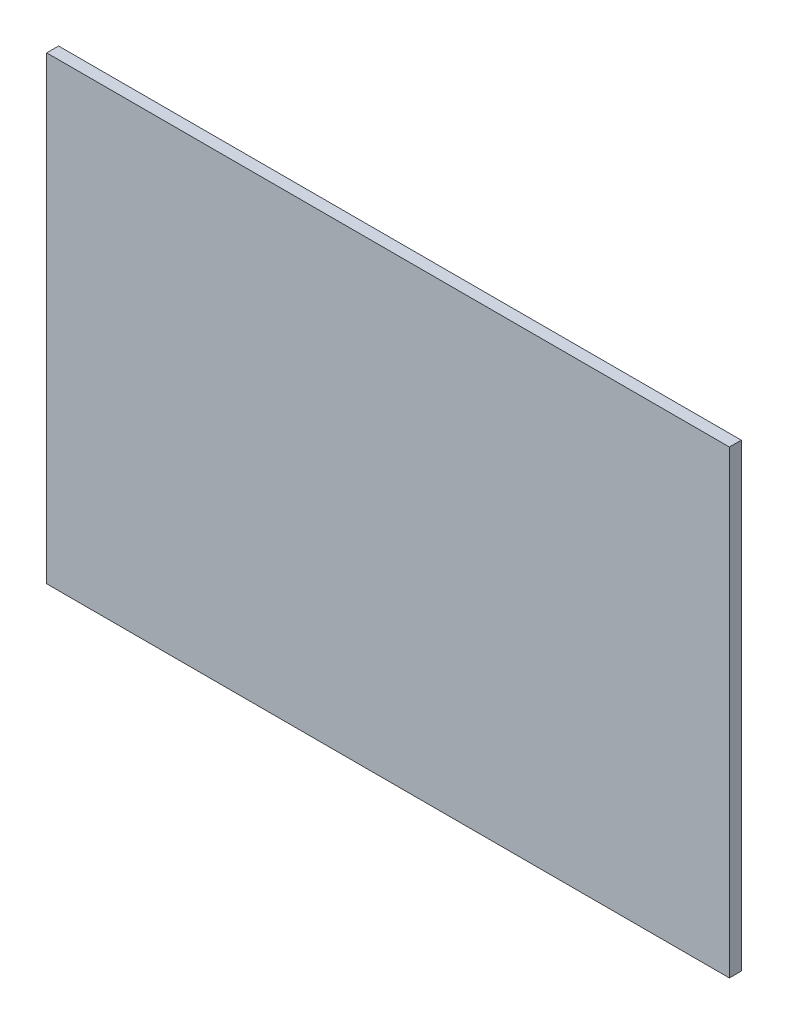
from build123d import *

# Parameters (mm, degrees)
SKETCH1_W           = 145.847538081
SKETCH1_H           = 98.237883514
BOSS_EXTRUDE1_DEPTH = 2.54


with BuildPart() as part:
    # Sketch1 → Boss-Extrude1 (new body)
    with BuildSketch(Plane.XY):
        with Locations((6.453461643, -18.542709895)):
            Rectangle(SKETCH1_W, SKETCH1_H)
    extrude(amount=BOSS_EXTRUDE1_DEPTH)


solid = part.part
